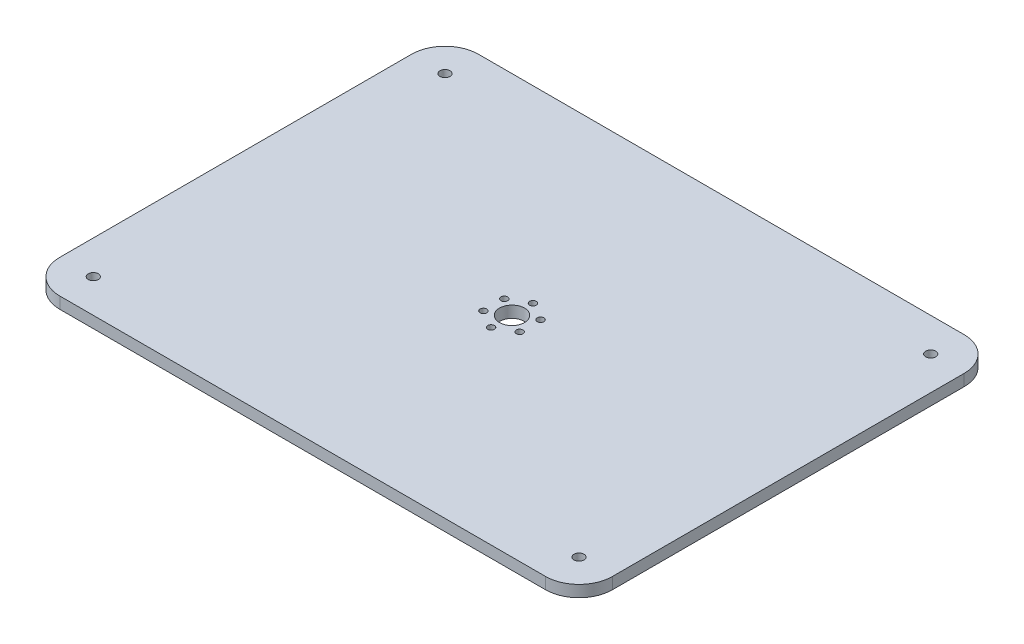
from build123d import *

# Parameters (mm, degrees)
SKETCH1_W           = 330
SKETCH1_H           = 250
BOSS_EXTRUDE1_DEPTH = 6.9
SKETCH2_R           = 3
CUT_EXTRUDE1_DEPTH  = 7.9
SKETCH3_R           = 2
SKETCH3_R_2         = 7.5
CUT_EXTRUDE2_DEPTH  = 7.9
FILLET1_R           = 20


with BuildPart() as part:
    # Sketch1 → Boss-Extrude1 (new body)
    with BuildSketch(Plane(origin=(0, 0, 0), x_dir=(1, 0, 0), z_dir=(0, 1, 0))):
        Rectangle(SKETCH1_W, SKETCH1_H)
    extrude(amount=BOSS_EXTRUDE1_DEPTH)

    # Sketch2 → Cut-Extrude1 (cut, through all)
    with BuildSketch(Plane(origin=(0, 6.9, 0), x_dir=(1, 0, 0), z_dir=(0, 1, 0))):
        with Locations((-145, 105)):
            Circle(SKETCH2_R)
        with Locations((145, 105)):
            Circle(SKETCH2_R)
        with Locations((145, -105)):
            Circle(SKETCH2_R)
        with Locations((-145, -105)):
            Circle(SKETCH2_R)
    extrude(amount=-CUT_EXTRUDE1_DEPTH, mode=Mode.SUBTRACT)

    # Sketch3 → Cut-Extrude2 (cut, through all)
    with BuildSketch(Plane(origin=(0, 6.9, 0), x_dir=(1, 0, 0), z_dir=(0, 1, 0))):
        with Locations((0, 12.5)):
            Circle(SKETCH3_R)
        with Locations((10.825317547, 6.25)):
            Circle(SKETCH3_R)
        with Locations((10.825317547, -6.25)):
            Circle(SKETCH3_R)
        with Locations((0, -12.5)):
            Circle(SKETCH3_R)
        with Locations((-10.825317547, -6.25)):
            Circle(SKETCH3_R)
        with Locations((-10.825317547, 6.25)):
            Circle(SKETCH3_R)
        Circle(SKETCH3_R_2)
    extrude(amount=-CUT_EXTRUDE2_DEPTH, mode=Mode.SUBTRACT)

    # Fillet1
    fillet1_edges = [part.edges().sort_by_distance(p)[0] for p in [
        (-165, 3.45, -125),
        (165, 3.45, -125),
        (165, 3.45, 125),
        (-165, 3.45, 125),
    ]]
    fillet(fillet1_edges, radius=FILLET1_R)


solid = part.part
